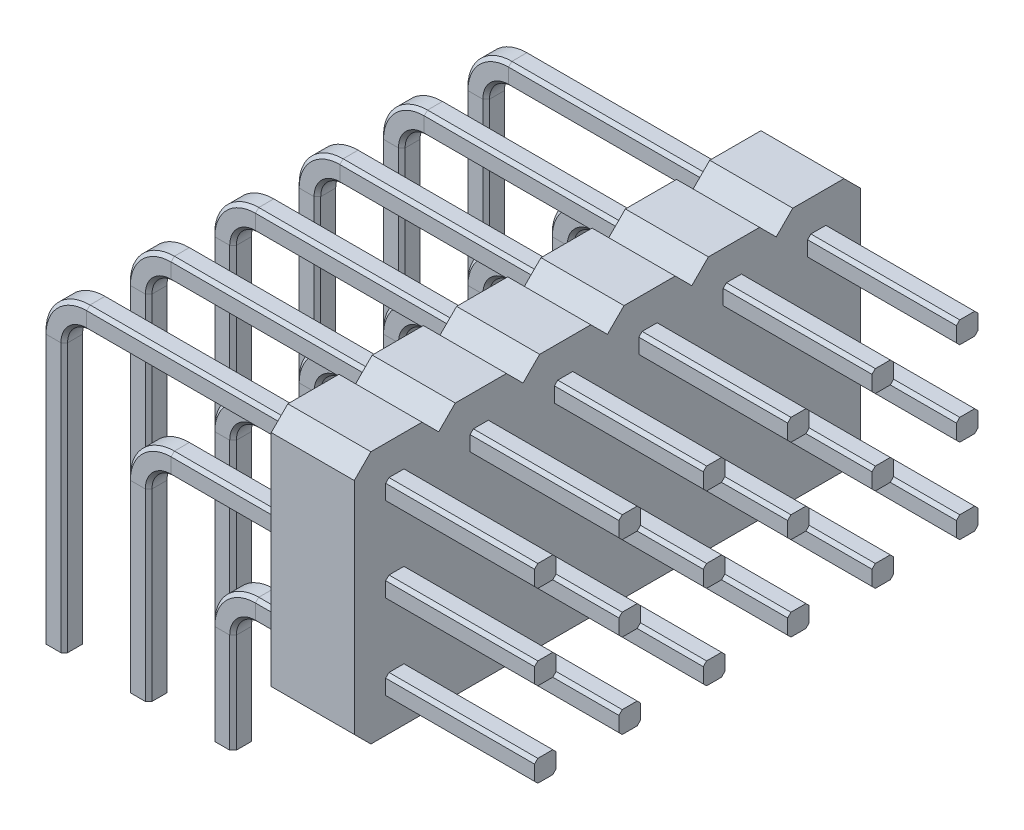
from build123d import *

# Parameters (mm, degrees)
BOSS_EXTRUDE1_DEPTH = 2.5
LPATTERN1_COUNT     = 6
LPATTERN1_PITCH     = 2.54


with BuildPart() as part:
    # Sweep1: sweep along a path in Sketch2
    with BuildLine(Plane.XY) as sweep1_path:
        Line((5.08, 0), (5.08, 3))
        ThreePointArc((5.08, 3), (5.372893219, 3.707106781), (6.08, 4))
        Line((6.08, 4), (14.48, 4))
    # Sketch1 → Sweep1 (sweep)
    with BuildSketch(Plane(origin=(0, 0, 0), x_dir=(1, 0, 0), z_dir=(0, 1, 0))):
        Polygon((4.855, 0.325), (5.305, 0.325), (5.405, 0.225), (5.405, -0.225), (5.305, -0.325), (4.855, -0.325), (4.755, -0.225), (4.755, 0.225), align=None)
    sweep(path=sweep1_path.line)



with BuildPart() as body_2:
    # Sweep2: sweep along a path in Sketch2_3
    with BuildLine(Plane.XY) as sweep2_path:
        Line((2.54, 0), (2.54, 5.54))
        ThreePointArc((2.54, 5.54), (2.832893219, 6.247106781), (3.54, 6.54))
        Line((3.54, 6.54), (14.48, 6.54))
    # Sketch1_4 → Sweep2 (sweep)
    with BuildSketch(Plane(origin=(0, 0, 0), x_dir=(1, 0, 0), z_dir=(0, 1, 0))):
        Polygon((2.315, 0.325), (2.765, 0.325), (2.865, 0.225), (2.865, -0.225), (2.765, -0.325), (2.315, -0.325), (2.215, -0.225), (2.215, 0.225), align=None)
    sweep(path=sweep2_path.line)


with BuildPart() as body_3:
    # Sweep3: sweep along a path in Sketch2_4
    with BuildLine(Plane.XY) as sweep3_path:
        Line((0, 0), (0, 8.08))
        ThreePointArc((0, 8.08), (0.292893219, 8.787106781), (1, 9.08))
        Line((1, 9.08), (14.48, 9.08))
    # Sketch1_5 → Sweep3 (sweep)
    with BuildSketch(Plane(origin=(0, 0, 0), x_dir=(1, 0, 0), z_dir=(0, 1, 0))):
        Polygon((-0.325, 0.225), (-0.225, 0.325), (0.225, 0.325), (0.325, 0.225), (0.325, -0.225), (0.225, -0.325), (-0.225, -0.325), (-0.325, -0.225), align=None)
    sweep(path=sweep3_path.line)


with BuildPart() as part_1:
    add(part.part)

    add(body_2.part)  # Boss-Extrude1 merges body 2

    add(body_3.part)  # Boss-Extrude1 merges body 3
    # Sketch3 → Boss-Extrude1 (add)
    with BuildSketch(Plane(origin=(7.5, 0, 0), x_dir=(0, 0, -1), z_dir=(1, 0, 0))):
        Polygon((-0.77, 10.35), (0.77, 10.35), (1.27, 9.85), (1.27, 3.23), (0.77, 2.73), (-0.77, 2.73), (-1.27, 3.23), (-1.27, 9.85), align=None)
    extrude(amount=BOSS_EXTRUDE1_DEPTH)


with BuildPart() as lpattern1_1:
    # LPattern1: pattern copy
    add(part_1.part.moved(Location(Vector(0, 0, -1) * (1 * LPATTERN1_PITCH))))


with BuildPart() as lpattern1_2:
    # LPattern1: pattern copy
    add(part_1.part.moved(Location(Vector(0, 0, -1) * (2 * LPATTERN1_PITCH))))


with BuildPart() as lpattern1_3:
    # LPattern1: pattern copy
    add(part_1.part.moved(Location(Vector(0, 0, -1) * (3 * LPATTERN1_PITCH))))


with BuildPart() as lpattern1_4:
    # LPattern1: pattern copy
    add(part_1.part.moved(Location(Vector(0, 0, -1) * (4 * LPATTERN1_PITCH))))


with BuildPart() as lpattern1_5:
    # LPattern1: pattern copy
    add(part_1.part.moved(Location(Vector(0, 0, -1) * (5 * LPATTERN1_PITCH))))


with BuildPart() as part_2:
    add(part_1.part)

    # Combine1: union LPattern1_1, LPattern1_2, LPattern1_3, LPattern1_4, LPattern1_5
    add(lpattern1_1.part)
    add(lpattern1_2.part)
    add(lpattern1_3.part)
    add(lpattern1_4.part)
    add(lpattern1_5.part)


solid = part_2.part
